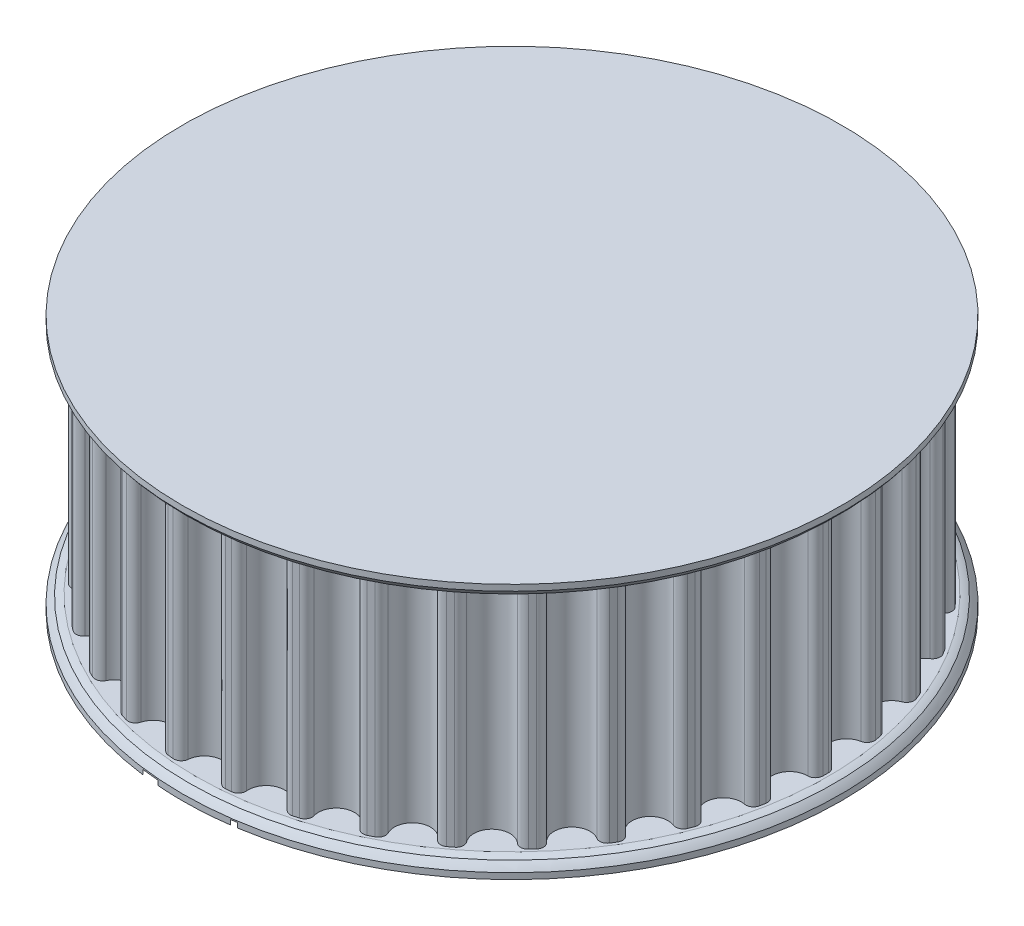
from build123d import *

# Parameters (mm, degrees)
SKETCH1_R               = 26.484839817
TOOTHOD_DEPTH           = 9.525
TOOTHPROFILE_DEPTH      = 20.05
TOOTHPATTERN_COUNT      = 34
LARGE_TOOTH_COUNT_DEPTH = 0.4


with BuildPart() as part:
    # Sketch1 → ToothOD (new body, symmetric)
    with BuildSketch(Plane(origin=(0, 0, 0), x_dir=(1, 0, 0), z_dir=(0, 1, 0))):
        Circle(SKETCH1_R)
    extrude(amount=TOOTHOD_DEPTH, both=True)

    # Sketch2 → ToothProfile (cut, through all)
    with BuildSketch(Plane(origin=(0, 9.525, 0), x_dir=(1, 0, 0), z_dir=(0, 1, 0))):
        with BuildLine():
            ThreePointArc((-1.519107163, 25.8159054), (0, 24.424839817), (1.519107163, 25.8159054))
            ThreePointArc((1.519107163, 25.8159054), (1.742690761, 26.245908095), (2.204508681, 26.392932418))
            ThreePointArc((2.204508681, 26.392932418), (0, 26.484839817), (-2.204508681, 26.392932418))
            ThreePointArc((-2.204508681, 26.392932418), (-1.742690761, 26.245908095), (-1.519107163, 25.8159054))
        make_face()
    toothprofile = extrude(amount=-TOOTHPROFILE_DEPTH, mode=Mode.SUBTRACT)

    # ToothPattern: ToothProfile ×34 about axis
    toothpattern_axis = Axis((0, 0, 0), (0, 1, 0))
    for i in range(1, TOOTHPATTERN_COUNT):
        add(toothprofile.rotate(toothpattern_axis, i * 360 / TOOTHPATTERN_COUNT), mode=Mode.SUBTRACT)

    # Sketch4 → Flange (revolve)
    with BuildSketch(Plane.XY):
        with BuildLine():
            Line((0, -9.525), (26.738839817, -9.525))
            ThreePointArc((26.738839817, -9.525), (27.030644924, -9.609570012), (27.310339817, -9.7282))
            ThreePointArc((27.310339817, -9.7282), (27.580863173, -9.992578767), (27.818339817, -10.287))
            Line((27.818339817, -10.287), (27.818339817, -10.795))
            Line((27.818339817, -10.795), (0, -10.795))
            Line((0, -10.795), (0, -9.525))
        make_face()
        with BuildLine():
            Line((27.818339817, 10.795), (27.818339817, 10.287))
            ThreePointArc((27.818339817, 10.287), (27.580863173, 9.992578767), (27.310339817, 9.7282))
            ThreePointArc((27.310339817, 9.7282), (27.030644924, 9.609570012), (26.738839817, 9.525))
            Line((26.738839817, 9.525), (0, 9.525))
            Line((0, 9.525), (0, 10.795))
            Line((0, 10.795), (27.818339817, 10.795))
        make_face()
    revolve(axis=Axis((0, 12.09802, 0), (0, -1, 0)))

    # Sketch9 → Large Tooth Count (cut)
    with BuildSketch(Plane(origin=(0, -10.795, 0), x_dir=(1, 0, 0), z_dir=(0, 1, 0))):
        with BuildLine():
            add(Edge.make_bspline(
                [(-2.903680392, 25.943753074), (-2.851306165, 25.951598605), (-2.749813536, 25.966801951), (-2.606342655, 26.01171696), (-2.477820869, 26.074829356), (-2.383034145, 26.141474043), (-2.31656786, 26.201818741), (-2.275403226, 26.251476626), (-2.241140048, 26.3035385), (-2.21373874, 26.358483075), (-2.194967795, 26.416915533), (-2.184535036, 26.478511543), (-2.180460317, 26.543000141), (-2.184542863, 26.586707653), (-2.186626485, 26.609014793)],
                knots=[0, 0, 0, 0, 0.000158702, 0.000307539, 0.000448911, 0.000586662, 0.000653641, 0.000717668, 0.000779586, 0.000840288, 0.000901285, 0.000962945, 0.001027338, 0.001094459, 0.001094459, 0.001094459, 0.001094459], degree=3))
            add(Edge.make_bspline(
                [(-2.186626485, 26.609014793), (-2.192736317, 26.642263395), (-2.204841324, 26.708136667), (-2.252304726, 26.799011284), (-2.320310586, 26.880039827), (-2.408886842, 26.949930675), (-2.515422148, 27.00569008), (-2.638369852, 27.040330812), (-2.775589729, 27.053435468), (-2.870665226, 27.046008843), (-2.920646798, 27.042104637)],
                knots=[0, 0, 0, 0, 0.000100933, 0.000199972, 0.000303329, 0.00041643, 0.000536251, 0.000661731, 0.000797233, 0.000947422, 0.000947422, 0.000947422, 0.000947422], degree=3))
            add(Edge.make_bspline(
                [(-2.920646798, 27.042104637), (-2.951994157, 27.038188089), (-3.011807649, 27.030714975), (-3.095504094, 27.011550945), (-3.169593717, 26.989796195), (-3.233557796, 26.96286107), (-3.289066622, 26.932002868), (-3.337685098, 26.89768825), (-3.380906258, 26.86063433), (-3.417778634, 26.81793884), (-3.450063255, 26.769000036), (-3.482679213, 26.713150464), (-3.514179092, 26.648093447), (-3.555840569, 26.552190943), (-3.604060115, 26.431428428), (-3.642458232, 26.335465549), (-3.660917892, 26.289331981)],
                knots=[0, 0, 0, 0, 9.4714e-05, 0.000180722, 0.000257273, 0.000326101, 0.000388462, 0.000447425, 0.000504379, 0.000558814, 0.000616026, 0.000680047, 0.000752729, 0.000832698, 0.000993713, 0.001142785, 0.001142785, 0.001142785, 0.001142785], degree=3))
            add(Edge.make_bspline(
                [(-3.660917892, 26.289331981), (-3.668534611, 26.277967871), (-3.684977223, 26.253435571), (-3.721124224, 26.221641179), (-3.767606688, 26.191248547), (-3.844463505, 26.15217931), (-3.955732123, 26.112847313), (-4.050506625, 26.097903768), (-4.099365548, 26.090199949)],
                knots=[0, 0, 0, 0, 4.0901e-05, 8.8296e-05, 0.00014303, 0.00020733, 0.000346567, 0.00049473, 0.00049473, 0.00049473, 0.00049473], degree=3))
            add(Edge.make_bspline(
                [(-4.099365548, 26.090199949), (-4.127672677, 26.088189931), (-4.183989265, 26.08419103), (-4.267936364, 26.098089151), (-4.350065974, 26.124298689), (-4.428141895, 26.164593018), (-4.498271748, 26.21797716), (-4.552765992, 26.286168199), (-4.589418709, 26.367042686), (-4.599550293, 26.425901454), (-4.60478586, 26.456317137)],
                knots=[0, 0, 0, 0, 8.4874e-05, 0.000168856, 0.000253292, 0.000342754, 0.000431176, 0.000515688, 0.000602006, 0.000694311, 0.000694311, 0.000694311, 0.000694311], degree=3))
            add(Edge.make_bspline(
                [(-4.60478586, 26.456317137), (-4.606775919, 26.486110091), (-4.610856114, 26.547194259), (-4.595834934, 26.640721121), (-4.566482452, 26.736563911), (-4.522574073, 26.834764286), (-4.46278021, 26.933421033), (-4.390906813, 27.03293457), (-4.302552849, 27.129442983), (-4.202213691, 27.225832499), (-4.087139141, 27.319087747), (-3.955632868, 27.404561535), (-3.809900724, 27.483859623), (-3.650050588, 27.556109603), (-3.477509856, 27.618964442), (-3.293530271, 27.671895273), (-3.098649622, 27.713200546), (-2.964252776, 27.730620438), (-2.895643673, 27.739513231)],
                knots=[0, 0, 0, 0, 8.9337e-05, 0.000183167, 0.000282041, 0.000389572, 0.00050489, 0.000627594, 0.000757222, 0.000896803, 0.001044769, 0.001200801, 0.001366639, 0.001542084, 0.001726557, 0.001917046, 0.002116, 0.002323486, 0.002323486, 0.002323486, 0.002323486], degree=3))
            add(Edge.make_bspline(
                [(-2.895643673, 27.739513231), (-2.833197303, 27.746085135), (-2.710317374, 27.759017113), (-2.528303156, 27.762384205), (-2.352245231, 27.757212197), (-2.18283183, 27.73794683), (-2.020665313, 27.70910294), (-1.867401036, 27.66897625), (-1.723859739, 27.618180407), (-1.590947357, 27.556650947), (-1.469396723, 27.486373446), (-1.360883573, 27.408483822), (-1.267896333, 27.321522894), (-1.188711806, 27.228553019), (-1.124261168, 27.129415775), (-1.074647958, 27.025523218), (-1.038691012, 26.917512279), (-1.027112533, 26.842906365), (-1.021302267, 26.805467918)],
                knots=[0, 0, 0, 0, 0.000188289, 0.00037051, 0.000545643, 0.00071634, 0.000881511, 0.001039407, 0.001191078, 0.001337704, 0.00147815, 0.001611753, 0.001737484, 0.001859138, 0.001977283, 0.002091115, 0.002203788, 0.002317283, 0.002317283, 0.002317283, 0.002317283], degree=3))
            add(Edge.make_bspline(
                [(-1.021302267, 26.805467918), (-1.017578481, 26.756355014), (-1.010313851, 26.660542019), (-1.027337989, 26.518235116), (-1.066552162, 26.383153916), (-1.129979673, 26.256167794), (-1.211389041, 26.136496876), (-1.307908548, 26.021850221), (-1.418382054, 25.911247143), (-1.501897565, 25.845299323), (-1.544581954, 25.811593699)],
                knots=[0, 0, 0, 0, 0.000147472, 0.0002877, 0.000427289, 0.000567465, 0.000711607, 0.000860583, 0.001016546, 0.001179588, 0.001179588, 0.001179588, 0.001179588], degree=3))
            add(Edge.make_bspline(
                [(-1.544581954, 25.811593699), (-1.500581201, 25.800497205), (-1.412904133, 25.778386037), (-1.285794324, 25.730759634), (-1.161888538, 25.6747271), (-1.043897132, 25.608258693), (-0.93364112, 25.535355057), (-0.835725701, 25.455310031), (-0.74998693, 25.370887741), (-0.679255659, 25.279663303), (-0.620273948, 25.184804166), (-0.575703088, 25.084632349), (-0.542297605, 24.980489056), (-0.531850182, 24.908422929), (-0.526597579, 24.872190574)],
                knots=[0, 0, 0, 0, 0.000136039, 0.000271076, 0.000406539, 0.000543664, 0.000676908, 0.000802567, 0.000922537, 0.001037039, 0.001148073, 0.001256785, 0.001365243, 0.001474907, 0.001474907, 0.001474907, 0.001474907], degree=3))
            add(Edge.make_bspline(
                [(-0.526597579, 24.872190574), (-0.523375579, 24.828159752), (-0.516902938, 24.739706734), (-0.528014131, 24.604846644), (-0.559575, 24.469671252), (-0.606741198, 24.333716349), (-0.672011816, 24.199309267), (-0.757239888, 24.069125965), (-0.860489233, 23.942807992), (-0.981994193, 23.822458624), (-1.118055971, 23.707854566), (-1.27038989, 23.604437996), (-1.435934333, 23.509501627), (-1.615404427, 23.425133328), (-1.807514746, 23.351112635), (-2.012977096, 23.29365268), (-2.229119196, 23.244754624), (-2.378406311, 23.22553318), (-2.45451711, 23.215733543)],
                knots=[0, 0, 0, 0, 0.000132307, 0.00026579, 0.000404004, 0.00054775, 0.000696715, 0.000851023, 0.0010135, 0.001185247, 0.001363378, 0.001546419, 0.001736814, 0.001935339, 0.002140817, 0.00235363, 0.00257485, 0.002804942, 0.002804942, 0.002804942, 0.002804942], degree=3))
            add(Edge.make_bspline(
                [(-2.45451711, 23.215733543), (-2.529454186, 23.208616672), (-2.675833245, 23.194714862), (-2.891542398, 23.1938641), (-3.097101559, 23.210610301), (-3.291292499, 23.244294937), (-3.472355489, 23.293063828), (-3.640002099, 23.350745382), (-3.793377106, 23.418171009), (-3.93119574, 23.496356336), (-4.0545611, 23.58109826), (-4.163512071, 23.670823207), (-4.260455668, 23.762482706), (-4.340734539, 23.858547975), (-4.406557425, 23.952763957), (-4.456190477, 24.042505757), (-4.491508556, 24.12588394), (-4.501760616, 24.181089014), (-4.506559298, 24.206928856)],
                knots=[0, 0, 0, 0, 0.000225736, 0.000440943, 0.000646136, 0.000843738, 0.001031315, 0.0012081, 0.0013752, 0.001533144, 0.00168275, 0.001823613, 0.001956236, 0.002082347, 0.002198519, 0.002300431, 0.002389808, 0.002468455, 0.002468455, 0.002468455, 0.002468455], degree=3))
            add(Edge.make_bspline(
                [(-4.506559298, 24.206928856), (-4.508518078, 24.238583634), (-4.512318945, 24.300007368), (-4.490068441, 24.389614199), (-4.448149823, 24.471502358), (-4.38394304, 24.542290622), (-4.306273769, 24.603341581), (-4.216254774, 24.650833642), (-4.116971753, 24.685798095), (-4.046352596, 24.696258841), (-4.010068673, 24.701633543)],
                knots=[0, 0, 0, 0, 9.4659e-05, 0.000183679, 0.00027314, 0.000368064, 0.000467921, 0.000568196, 0.000672119, 0.00078194, 0.00078194, 0.00078194, 0.00078194], degree=3))
            add(Edge.make_bspline(
                [(-4.010068673, 24.701633543), (-3.986562796, 24.703806011), (-3.939847392, 24.708123558), (-3.869490842, 24.702429253), (-3.799443667, 24.691704973), (-3.732597269, 24.670698752), (-3.67165569, 24.64702383), (-3.620795793, 24.620227966), (-3.581063445, 24.591932077), (-3.563445705, 24.568410445), (-3.555547579, 24.557865574)],
                knots=[0, 0, 0, 0, 7.0686e-05, 0.00014048, 0.000211093, 0.000282853, 0.000350176, 0.000406906, 0.000455308, 0.000494639, 0.000494639, 0.000494639, 0.000494639], degree=3))
            add(Edge.make_bspline(
                [(-3.555547579, 24.557865574), (-3.535128513, 24.526534669), (-3.495550308, 24.465806084), (-3.435909325, 24.378562949), (-3.37613926, 24.299707203), (-3.31814652, 24.227309697), (-3.259900261, 24.163627702), (-3.204135254, 24.105470335), (-3.147484612, 24.056934), (-3.092708944, 24.013420069), (-3.035042054, 23.97814039), (-2.974402446, 23.948090678), (-2.908650473, 23.926372389), (-2.839686882, 23.90941739), (-2.767176595, 23.897281714), (-2.690609966, 23.893690433), (-2.610021165, 23.894040231), (-2.555098657, 23.899577994), (-2.526847579, 23.902426512)],
                knots=[0, 0, 0, 0, 0.000112195, 0.000217467, 0.000316943, 0.000408989, 0.000495607, 0.0005758, 0.000650479, 0.000719243, 0.000785408, 0.000852902, 0.000921805, 0.000992626, 0.001065882, 0.001141916, 0.001222288, 0.00130742, 0.00130742, 0.00130742, 0.00130742], degree=3))
            add(Edge.make_bspline(
                [(-2.526847579, 23.902426512), (-2.490395028, 23.907648975), (-2.418253984, 23.917984436), (-2.312625249, 23.946327215), (-2.21077193, 23.984901519), (-2.112701825, 24.032826403), (-2.020989929, 24.090035393), (-1.939239807, 24.157475067), (-1.867773928, 24.233368154), (-1.807340221, 24.31680936), (-1.758751726, 24.406606679), (-1.729802956, 24.502832517), (-1.71474827, 24.602771382), (-1.720332884, 24.670059679), (-1.723175704, 24.704312449)],
                knots=[0, 0, 0, 0, 0.000110396, 0.000218479, 0.000327278, 0.000436702, 0.000545461, 0.000650764, 0.000753734, 0.000857334, 0.000959187, 0.001058323, 0.001157458, 0.001260247, 0.001260247, 0.001260247, 0.001260247], degree=3))
            add(Edge.make_bspline(
                [(-1.723175704, 24.704312449), (-1.726915687, 24.729691617), (-1.734193648, 24.779079167), (-1.752050523, 24.850465422), (-1.776793218, 24.916934883), (-1.80971511, 24.977711892), (-1.846867472, 25.034841911), (-1.8920284, 25.085845068), (-1.943575513, 25.131543291), (-2.00056562, 25.173098115), (-2.06440847, 25.207169976), (-2.132361257, 25.237540902), (-2.206426912, 25.259085623), (-2.284768227, 25.276541484), (-2.368560869, 25.285972301), (-2.457157105, 25.289039381), (-2.551180947, 25.28793241), (-2.615286422, 25.281110611), (-2.648291329, 25.277598387)],
                knots=[0, 0, 0, 0, 7.6925e-05, 0.000149695, 0.000220347, 0.000289053, 0.000356666, 0.000424373, 0.000492672, 0.000563052, 0.000635388, 0.000709375, 0.000785926, 0.000866318, 0.000949943, 0.001038419, 0.001132198, 0.001231719, 0.001231719, 0.001231719, 0.001231719], degree=3))
            add(Edge.make_bspline(
                [(-2.648291329, 25.277598387), (-2.661383912, 25.27578839), (-2.691446524, 25.271632355), (-2.742324966, 25.265257054), (-2.803865472, 25.252319101), (-2.872810982, 25.240581323), (-2.940410552, 25.226869848), (-2.999045189, 25.218145429), (-3.043737488, 25.209171809), (-3.069162195, 25.205770626), (-3.079595235, 25.204374949)],
                knots=[0, 0, 0, 0, 3.9654e-05, 9.1052e-05, 0.000153751, 0.00022819, 0.000300872, 0.000360621, 0.000405987, 0.000437558, 0.000437558, 0.000437558, 0.000437558], degree=3))
            add(Edge.make_bspline(
                [(-3.079595235, 25.204374949), (-3.115287372, 25.20136448), (-3.183115205, 25.19564351), (-3.280826076, 25.201841697), (-3.368451735, 25.220038701), (-3.445423597, 25.251135131), (-3.510475303, 25.294557579), (-3.558875908, 25.352227923), (-3.594124682, 25.420447397), (-3.602225433, 25.471537972), (-3.606446798, 25.498161668)],
                knots=[0, 0, 0, 0, 0.000107338, 0.000203981, 0.000292606, 0.000374691, 0.000451725, 0.000524561, 0.00059844, 0.000678832, 0.000678832, 0.000678832, 0.000678832], degree=3))
            add(Edge.make_bspline(
                [(-3.606446798, 25.498161668), (-3.608124353, 25.525100407), (-3.611394467, 25.577613001), (-3.587590428, 25.653898629), (-3.545264953, 25.722942815), (-3.481444124, 25.782842329), (-3.399998249, 25.834719942), (-3.300420811, 25.875853294), (-3.184421111, 25.908251541), (-3.10063372, 25.91979602), (-3.056378048, 25.925893699)],
                knots=[0, 0, 0, 0, 8.0367e-05, 0.000156662, 0.000235228, 0.000321111, 0.000416722, 0.000523539, 0.000643133, 0.000777019, 0.000777019, 0.000777019, 0.000777019], degree=3))
            Line((-3.056378048, 25.925893699), (-2.903680392, 25.943753074))
        make_face()
        with BuildLine():
            Line((3.084861359, 23.598726733), (3.143797296, 24.076465014))
            Line((3.143797296, 24.076465014), (1.338214484, 24.298814233))
            add(Edge.make_bspline(
                [(1.338214484, 24.298814233), (1.308095108, 24.302940833), (1.249687214, 24.310943193), (1.16537298, 24.328190265), (1.087072534, 24.348184297), (1.014998447, 24.372705155), (0.948533054, 24.399774325), (0.888973905, 24.432378824), (0.834370179, 24.466840428), (0.787368557, 24.506516218), (0.745698381, 24.548162806), (0.71174645, 24.593721074), (0.682505307, 24.640780803), (0.661268177, 24.691522293), (0.645519327, 24.744471335), (0.638360473, 24.800127659), (0.634753141, 24.858182805), (0.638746903, 24.897415256), (0.64080589, 24.917641576)],
                knots=[0, 0, 0, 0, 9.1179e-05, 0.000176816, 0.000258037, 0.000333433, 0.000405077, 0.000472995, 0.000536897, 0.000598408, 0.000657134, 0.000713214, 0.000768498, 0.000822904, 0.000877732, 0.000933677, 0.000990889, 0.001051775, 0.001051775, 0.001051775, 0.001051775], degree=3))
            add(Edge.make_bspline(
                [(0.64080589, 24.917641576), (0.644829625, 24.940276874), (0.652902529, 24.985690546), (0.684861891, 25.050353895), (0.730392323, 25.111684159), (0.78743677, 25.171147471), (0.850594105, 25.227646946), (0.913510974, 25.283341204), (0.979472611, 25.331656404), (1.027115598, 25.356368736), (1.050678546, 25.368590795)],
                knots=[0, 0, 0, 0, 6.8672e-05, 0.000137777, 0.000213868, 0.000297255, 0.000384474, 0.00046806, 0.00054934, 0.000628875, 0.000628875, 0.000628875, 0.000628875], degree=3))
            Line((1.050678546, 25.368590795), (3.292923078, 27.241146264))
            add(Edge.make_bspline(
                [(3.292923078, 27.241146264), (3.328655314, 27.270680297), (3.395872649, 27.326237945), (3.494511509, 27.398841858), (3.580976611, 27.46049232), (3.659392785, 27.509877437), (3.736139372, 27.547548068), (3.817970823, 27.568595509), (3.905470821, 27.577013378), (3.965046555, 27.571633136), (3.995689484, 27.568865795)],
                knots=[0, 0, 0, 0, 0.000139042, 0.000261558, 0.00036734, 0.000457548, 0.000539438, 0.000622614, 0.000709604, 0.000801736, 0.000801736, 0.000801736, 0.000801736], degree=3))
            add(Edge.make_bspline(
                [(3.995689484, 27.568865795), (4.022828958, 27.565022311), (4.075291045, 27.557592646), (4.150501019, 27.541558487), (4.219879194, 27.521547871), (4.284071464, 27.499358648), (4.341796807, 27.470655849), (4.394502148, 27.440346016), (4.440887846, 27.404491659), (4.481976555, 27.365602754), (4.517161403, 27.322412365), (4.546075284, 27.275184669), (4.569201695, 27.22451526), (4.586322838, 27.169889164), (4.597783006, 27.111499412), (4.604004219, 27.049324103), (4.604050622, 26.983200831), (4.599178867, 26.938399796), (4.596657453, 26.91521267)],
                knots=[0, 0, 0, 0, 8.2216e-05, 0.000158928, 0.000230438, 0.000298796, 0.000362297, 0.000423555, 0.000480886, 0.000537728, 0.000592955, 0.000647478, 0.000703422, 0.000759622, 0.000818815, 0.000881634, 0.000946821, 0.001016753, 0.001016753, 0.001016753, 0.001016753], degree=3))
            Line((4.596657453, 26.91521267), (4.321623078, 24.68636267))
            Line((4.321623078, 24.68636267), (4.367164484, 24.681004858))
            add(Edge.make_bspline(
                [(4.367164484, 24.681004858), (4.416977233, 24.673903819), (4.512695914, 24.660258677), (4.649436255, 24.630308201), (4.772664008, 24.590863041), (4.866410349, 24.552284589), (4.933111444, 24.516803796), (4.9743273, 24.48513322), (5.009306941, 24.450321187), (5.035281389, 24.410205283), (5.054398323, 24.366782188), (5.065940548, 24.319394398), (5.070728142, 24.2681461), (5.067258311, 24.233019194), (5.065466046, 24.21487517)],
                knots=[0, 0, 0, 0, 0.000150922, 0.000290008, 0.00041935, 0.000538597, 0.000593759, 0.000645374, 0.000693997, 0.000741054, 0.00078784, 0.000835703, 0.000886798, 0.000941386, 0.000941386, 0.000941386, 0.000941386], degree=3))
            add(Edge.make_bspline(
                [(5.065466046, 24.21487517), (5.060016471, 24.186610455), (5.049322017, 24.131142698), (5.003811006, 24.057863809), (4.937268198, 23.999976568), (4.850938443, 23.957731682), (4.747172927, 23.928927042), (4.626277645, 23.91472785), (4.48918039, 23.914427872), (4.39300182, 23.924042716), (4.342161359, 23.92912517)],
                knots=[0, 0, 0, 0, 8.5767e-05, 0.000168312, 0.000253074, 0.000347323, 0.000454159, 0.000574776, 0.000711403, 0.000864611, 0.000864611, 0.000864611, 0.000864611], degree=3))
            Line((4.342161359, 23.92912517), (4.229647296, 23.94341267))
            Line((4.229647296, 23.94341267), (4.170711359, 23.465674389))
            add(Edge.make_bspline(
                [(4.170711359, 23.465674389), (4.164881025, 23.429518864), (4.153641665, 23.359820466), (4.11092165, 23.264976142), (4.05182001, 23.183919333), (3.974715915, 23.119247971), (3.88293725, 23.071482095), (3.778199619, 23.042035561), (3.661426004, 23.031701453), (3.580722238, 23.038729423), (3.538489484, 23.042407201)],
                knots=[0, 0, 0, 0, 0.000109457, 0.000211004, 0.000308698, 0.000408171, 0.000510024, 0.00061686, 0.00073255, 0.000859553, 0.000859553, 0.000859553, 0.000859553], degree=3))
            add(Edge.make_bspline(
                [(3.538489484, 23.042407201), (3.502533007, 23.048475792), (3.433114736, 23.060191929), (3.335921266, 23.094751845), (3.25214701, 23.146225524), (3.180497964, 23.210142672), (3.125791504, 23.289581072), (3.090235639, 23.382122727), (3.076541169, 23.487437904), (3.081991719, 23.560343127), (3.084861359, 23.598726733)],
                knots=[0, 0, 0, 0, 0.000109278, 0.000210975, 0.000307151, 0.000402598, 0.00049697, 0.00059365, 0.000697331, 0.00081261, 0.00081261, 0.00081261, 0.00081261], degree=3))
        make_face()
        Polygon((1.811487921, 24.994436889), (3.235773078, 24.819415014), (3.433119171, 26.419615014), align=None, mode=Mode.SUBTRACT)
    large_tooth_count = extrude(amount=LARGE_TOOTH_COUNT_DEPTH, mode=Mode.SUBTRACT)

    # Mirror1: Large Tooth Count across plane
    add(large_tooth_count.mirror(Plane.XY), mode=Mode.SUBTRACT)


solid = part.part
